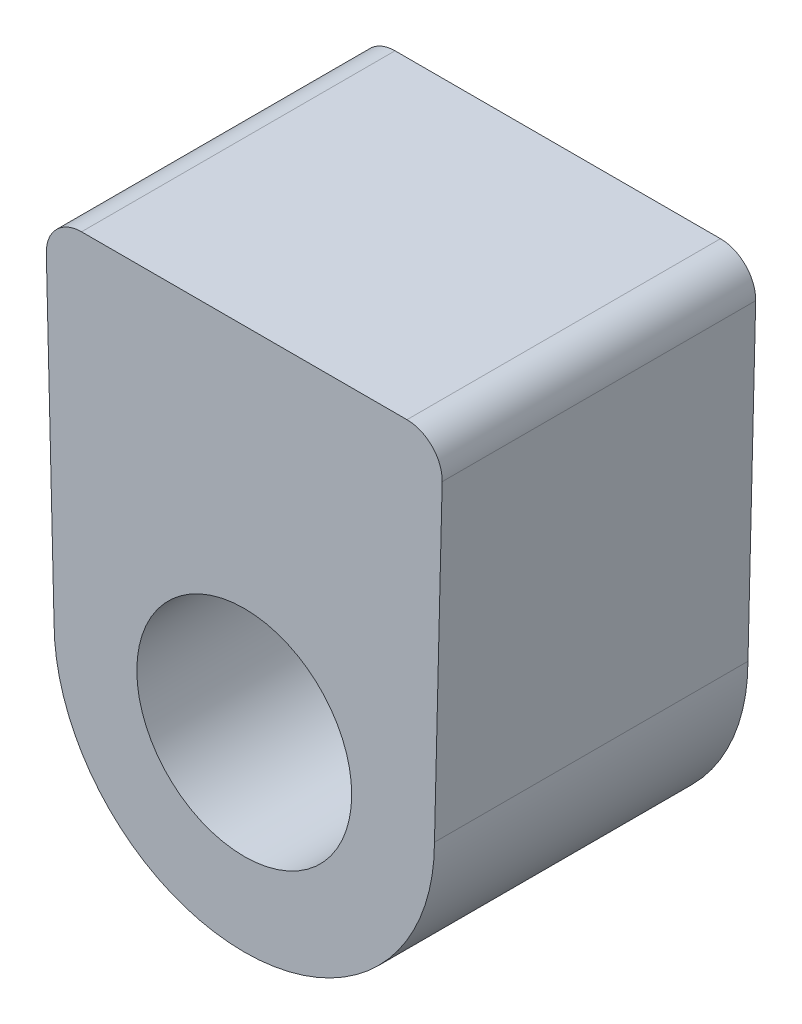
from build123d import *

# Parameters (mm, degrees)
BOSS_EXTRUDE1_DEPTH           = 4.45
BOSS_EXTRUDE1_DEPTH_BACK      = 4.45
SKETCH1_R                     = 3.05
TAP_DRILL_FOR_M1_6_TAP1_D     = 1.25
TAP_DRILL_FOR_M1_6_TAP1_DEPTH = 5
FILLET1_R                     = 1


with BuildPart() as part:
    # Sketch1 → Boss-Extrude1 (new, two sides: drawn at the far end of the back side and taken through both)
    with BuildSketch(Plane.XY.offset(-BOSS_EXTRUDE1_DEPTH_BACK)):
        with BuildLine():
            Line((-5.4, 0), (-5.644394736, 10))
            Line((-5.644394736, 10), (5.644394736, 10))
            Line((5.644394736, 10), (5.4, 0))
            ThreePointArc((5.4, 0), (0, -5.4), (-5.4, 0))
        make_face()
        Circle(SKETCH1_R, mode=Mode.SUBTRACT)
    extrude(amount=BOSS_EXTRUDE1_DEPTH + BOSS_EXTRUDE1_DEPTH_BACK)

    # Tap Drill for M1.6 Tap1
    with Locations(Plane(origin=(0, 0, -4.45), x_dir=(-1, 0, 0), z_dir=(0, 0, -1))):
        with Locations((-2.5, 7.75), (2.5, 7.75)):
            Hole(TAP_DRILL_FOR_M1_6_TAP1_D / 2, depth=TAP_DRILL_FOR_M1_6_TAP1_DEPTH)

    # Fillet1
    fillet1_edges = [part.edges().sort_by_distance(p)[0] for p in [
        (-5.644394736, 10, 0),
        (5.644394736, 10, 0),
    ]]
    fillet(fillet1_edges, radius=FILLET1_R)


solid = part.part
